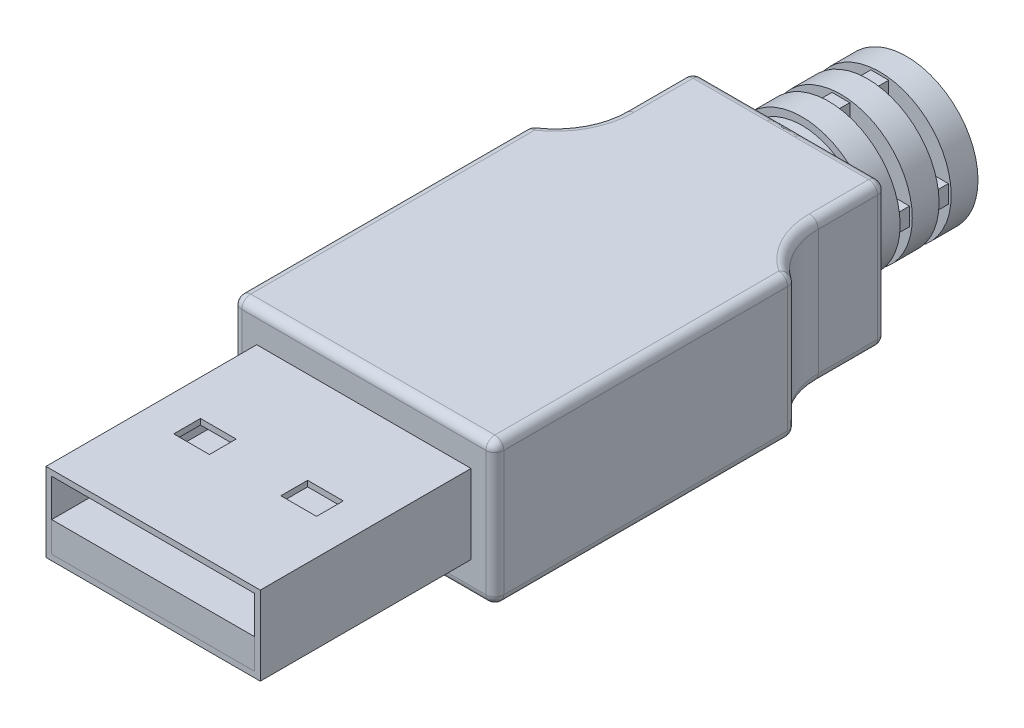
from build123d import *

# Parameters (mm, degrees)
SKETCH1_W           = 12
SKETCH1_H           = 4.42
SKETCH1_W_2         = 11.36
SKETCH1_H_2         = 2.1
BOSS_EXTRUDE1_DEPTH = 11.8
CUT_EXTRUDE1_REACH  = 15.956
SKETCH4_W           = 2
SKETCH4_H           = 1.5
SKETCH5_W           = 14.67
SKETCH5_H           = 8
BOSS_EXTRUDE2_DEPTH = 23.85
CUT_EXTRUDE2_DEPTH  = 38.26559707
BOSS_EXTRUDE4_START = 1
BOSS_EXTRUDE4_DEPTH = 5.5
SKETCH9_W           = 4
SKETCH9_H           = 1.5
FILLET1_R           = 0.5


with BuildPart() as part:
    # Sketch1 → Boss-Extrude1 (new body)
    with BuildSketch(Plane.XY):
        Rectangle(SKETCH1_W, SKETCH1_H)
        with Locations((0, 0.84)):
            Rectangle(SKETCH1_W_2, SKETCH1_H_2, mode=Mode.SUBTRACT)
    extrude(amount=-BOSS_EXTRUDE1_DEPTH)

    # Sketch4 → Cut-Extrude1 (cut, up to next)
    with BuildSketch(Plane(origin=(0, 2.21, 0), x_dir=(1, 0, 0), z_dir=(0, 1, 0)), mode=Mode.PRIVATE) as cut_extrude1_sk1:
        with Locations((3, 5.9)):
            Rectangle(SKETCH4_W, SKETCH4_H)
    cut_extrude1_tool1 = extrude(cut_extrude1_sk1.sketch, amount=-CUT_EXTRUDE1_REACH, mode=Mode.PRIVATE) & part.part
    # Sketch4 → Cut-Extrude1 (cut, up to next)
    with BuildSketch(Plane(origin=(0, 2.21, 0), x_dir=(1, 0, 0), z_dir=(0, 1, 0)), mode=Mode.PRIVATE) as cut_extrude1_sk2:
        with Locations((-3, 5.9)):
            Rectangle(SKETCH4_W, SKETCH4_H)
    cut_extrude1_tool2 = extrude(cut_extrude1_sk2.sketch, amount=-CUT_EXTRUDE1_REACH, mode=Mode.PRIVATE) & part.part
    add(cut_extrude1_tool1.solids().sort_by_distance((3, 2.21, -5.9))[0], mode=Mode.SUBTRACT)
    add(cut_extrude1_tool2.solids().sort_by_distance((-3, 2.21, -5.9))[0], mode=Mode.SUBTRACT)

    # Sketch5 → Boss-Extrude2 (add)
    with BuildSketch(Plane(origin=(0, 0, -11.8), x_dir=(-1, 0, 0), z_dir=(0, 0, -1))):
        Rectangle(SKETCH5_W, SKETCH5_H)
    extrude(amount=BOSS_EXTRUDE2_DEPTH)

    # Sketch6 → Cut-Extrude2 (cut, through all)
    with BuildSketch(Plane(origin=(0, 4, 0), x_dir=(1, 0, 0), z_dir=(0, 1, 0))):
        with BuildLine():
            Line((7.335, 35.65), (5.415, 35.65))
            Line((5.415, 35.65), (5.415, 31.83))
            ThreePointArc((5.415, 31.83), (5.928851746, 29.89505814), (7.335, 28.47))
            Line((7.335, 28.47), (7.335, 35.65))
        make_face()
        with BuildLine():
            Line((-5.415, 31.83), (-5.415, 35.65))
            Line((-5.415, 35.65), (-7.335, 35.65))
            Line((-7.335, 35.65), (-7.335, 28.47))
            ThreePointArc((-7.335, 28.47), (-5.928851746, 29.89505814), (-5.415, 31.83))
        make_face()
    extrude(amount=-CUT_EXTRUDE2_DEPTH, mode=Mode.SUBTRACT)

    # Sketch9 → Revolve1 (revolve)
    with BuildSketch(Plane(origin=(0, 0, 0), x_dir=(1, 0, 0), z_dir=(0, 1, 0))):
        with Locations((2, 41.44)):
            Rectangle(SKETCH9_W, SKETCH9_H)
        with Locations((2, 39.26)):
            Rectangle(SKETCH9_W, SKETCH9_H)
        Polygon((0, 37.83), (0, 35.65), (3.585, 35.65), (3.585, 36.33), (4, 36.33), (4, 37.83), align=None)
    revolve(axis=Axis((0, 0, -35.65), (0, 0, -1)))


with BuildPart() as body_2:
    # Sketch8 → Boss-Extrude4 (new body)
    with BuildSketch(Plane(origin=(0, 0, -35.65), x_dir=(-1, 0, 0), z_dir=(0, 0, -1)).offset(BOSS_EXTRUDE4_START)):
        with BuildLine():
            Line((0, 3.842606537), (-0.5, 3.842606537))
            Line((-0.5, 3.842606537), (-0.5, 1.833030278))
            ThreePointArc((-0.5, 1.833030278), (-1.343502884, 1.343502884), (-1.833030278, 0.5))
            Line((-1.833030278, 0.5), (-3.842606537, 0.5))
            Line((-3.842606537, 0.5), (-3.842606537, 0))
            Line((-3.842606537, 0), (-3.842606537, -0.5))
            Line((-3.842606537, -0.5), (-1.833030278, -0.5))
            ThreePointArc((-1.833030278, -0.5), (-1.343502884, -1.343502884), (-0.5, -1.833030278))
            Line((-0.5, -1.833030278), (-0.5, -3.842606537))
            Line((-0.5, -3.842606537), (0, -3.842606537))
            Line((0, -3.842606537), (0.5, -3.842606537))
            Line((0.5, -3.842606537), (0.5, -1.833030278))
            ThreePointArc((0.5, -1.833030278), (1.343502884, -1.343502884), (1.833030278, -0.5))
            Line((1.833030278, -0.5), (3.842606537, -0.5))
            Line((3.842606537, -0.5), (3.842606537, 0))
            Line((3.842606537, 0), (3.842606537, 0.5))
            Line((3.842606537, 0.5), (1.833030278, 0.5))
            ThreePointArc((1.833030278, 0.5), (1.343502884, 1.343502884), (0.5, 1.833030278))
            Line((0.5, 1.833030278), (0.5, 3.842606537))
            Line((0.5, 3.842606537), (0, 3.842606537))
        make_face()
    extrude(amount=BOSS_EXTRUDE4_DEPTH)


with BuildPart() as revolve1_piece_1:
    # of the separate pieces the step leaves, piece 1, a body of its own (revolve1_pieces)
    add(part.part.solids().sort_by_distance((-7.335, -4, -11.8))[0])

    # Fillet1
    fillet1_edges = [revolve1_piece_1.edges().sort_by_distance(p)[0] for p in [
        (-5.928851746, -4, -29.89505814),
        (5.928851746, -4, -29.89505814),
        (7.335, 4, -20.135),
        (0, 4, -11.8),
        (-7.335, 4, -20.135),
        (-5.928851746, 4, -29.89505814),
        (-5.415, 4, -33.74),
        (0, 4, -35.65),
        (5.415, 4, -33.74),
        (5.928851746, 4, -29.89505814),
        (0, -4, -35.65),
        (0, -4, -11.8),
        (-5.415, 0, -35.65),
        (5.415, 0, -35.65),
        (7.335, 0, -11.8),
        (7.335, 0, -28.47),
        (-7.335, 0, -28.47),
        (-7.335, 0, -11.8),
        (-7.335, -4, -20.135),
        (-5.415, -4, -33.74),
        (5.415, -4, -33.74),
        (7.335, -4, -20.135),
    ]]
    fillet(fillet1_edges, radius=FILLET1_R)


with BuildPart() as revolve1_piece_2:
    # of the separate pieces the step leaves, piece 2, a body of its own (revolve1_pieces)
    add(part.part.solids().sort_by_distance((4, 0, -38.51))[0])


with BuildPart() as revolve1_piece_3:
    # of the separate pieces the step leaves, piece 3, a body of its own (revolve1_pieces)
    add(part.part.solids().sort_by_distance((4, 0, -40.69))[0])


solid = Compound([body_2.part, revolve1_piece_1.part, revolve1_piece_2.part, revolve1_piece_3.part])
